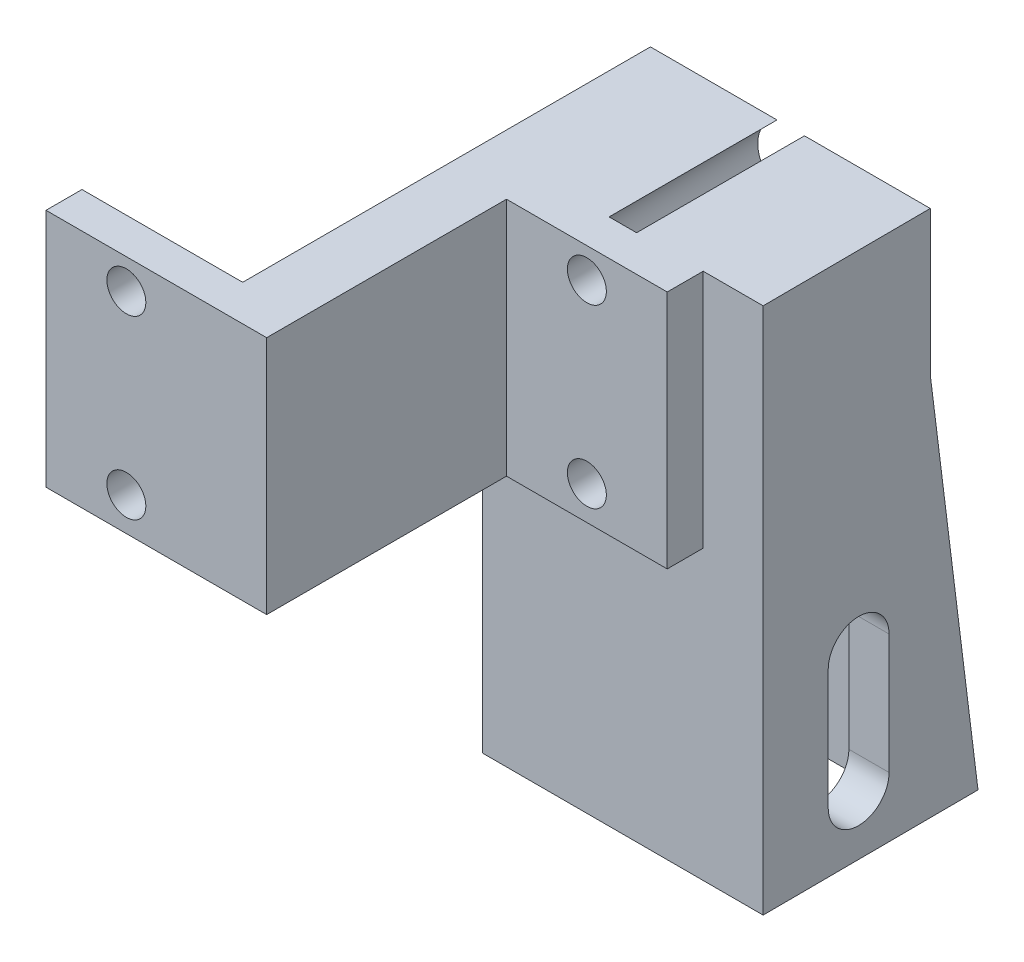
from build123d import *

# Parameters (mm, degrees)
BOSS_EXTRUDE1_DEPTH = 20
CUT_EXTRUDE1_START  = -4
SKETCH2_R           = 1.625
CUT_EXTRUDE1_DEPTH  = 25
BOSS_EXTRUDE2_DEPTH = 23.4
SKETCH5_R           = 2.75
CUT_EXTRUDE2_DEPTH  = 19
CUT_EXTRUDE3_DEPTH  = 45
CUT_EXTRUDE4_DEPTH  = 20


with BuildPart() as part:
    # Sketch1 → Boss-Extrude1 (new body)
    with BuildSketch(Plane(origin=(0, 0, 0), x_dir=(1, 0, 0), z_dir=(0, 1, 0))):
        Polygon((0, 0), (18.4, 0), (18.4, 20), (31.8, 20), (31.8, 23), (13.4, 23), (13.4, 3), (0, 3), align=None)
    extrude(amount=BOSS_EXTRUDE1_DEPTH)

    # Sketch2 → Cut-Extrude1 (cut)
    with BuildSketch(Plane.XY.offset(-20).offset(CUT_EXTRUDE1_START)):
        with Locations((25.1, 17.5)):
            Circle(SKETCH2_R)
        with Locations((25.1, 2.8)):
            Circle(SKETCH2_R)
    cut_extrude1 = extrude(amount=CUT_EXTRUDE1_DEPTH, mode=Mode.SUBTRACT)

    # Mirror1: Cut-Extrude1 across plane
    add(cut_extrude1.mirror(Plane.ZY.offset(-15.9)), mode=Mode.SUBTRACT)

    # Sketch3 → Boss-Extrude2 (add)
    with BuildSketch(Plane.ZY.offset(-13.4)):
        Polygon((-23, 20), (-23, -24), (-41, -24), (-37, 8), (-37, 20), align=None)
        with BuildLine():
            Line((-28.45, -9), (-28.45, -19))
            ThreePointArc((-28.45, -19), (-31, -21.55), (-33.55, -19))
            Line((-33.55, -19), (-33.55, -9))
            ThreePointArc((-33.55, -9), (-31, -6.45), (-28.45, -9))
        make_face(mode=Mode.SUBTRACT)
    extrude(amount=-BOSS_EXTRUDE2_DEPTH)

    # Sketch5 → Cut-Extrude2 (cut, through all)
    with BuildSketch(Plane.XY.offset(-23)):
        with Locations((25.1, 17.5)):
            Circle(SKETCH5_R)
        with Locations((25.1, 2.8)):
            Circle(SKETCH5_R)
    extrude(amount=-CUT_EXTRUDE2_DEPTH, mode=Mode.SUBTRACT)

    # Sketch4 → Cut-Extrude3 (cut, through all)
    with BuildSketch(Plane.XZ.offset(24)):
        Polygon((36.8, -23), (36.71517637, -41), (36.8, -41), align=None)
    extrude(amount=-CUT_EXTRUDE3_DEPTH, mode=Mode.SUBTRACT)

    # Sketch7 → Cut-Extrude4 (cut)
    with BuildSketch(Plane.ZY.offset(-13.4)):
        with BuildLine():
            Line((-37, -9), (-37, -24))
            Line((-37, -24), (-25, -24))
            Line((-25, -24), (-25, -9))
            ThreePointArc((-25, -9), (-31, -3), (-37, -9))
        make_face()
    extrude(amount=-CUT_EXTRUDE4_DEPTH, mode=Mode.SUBTRACT)


solid = part.part
